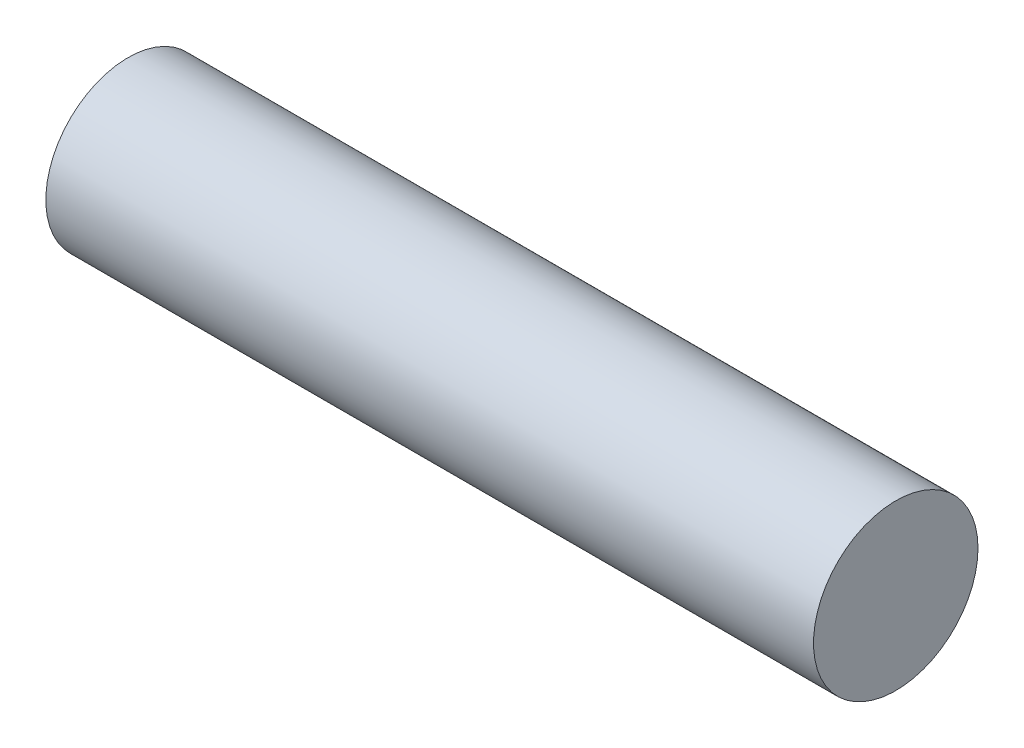
from build123d import *

# Parameters (mm, degrees)
SKETCH1_R           = 7.5
BOSS_EXTRUDE1_DEPTH = 35


with BuildPart() as part:
    # Sketch1 → Boss-Extrude1 (new body, symmetric)
    with BuildSketch(Plane(origin=(0, 0, 0), x_dir=(0, 0, -1), z_dir=(1, 0, 0))):
        Circle(SKETCH1_R)
    extrude(amount=BOSS_EXTRUDE1_DEPTH, both=True)


solid = part.part
